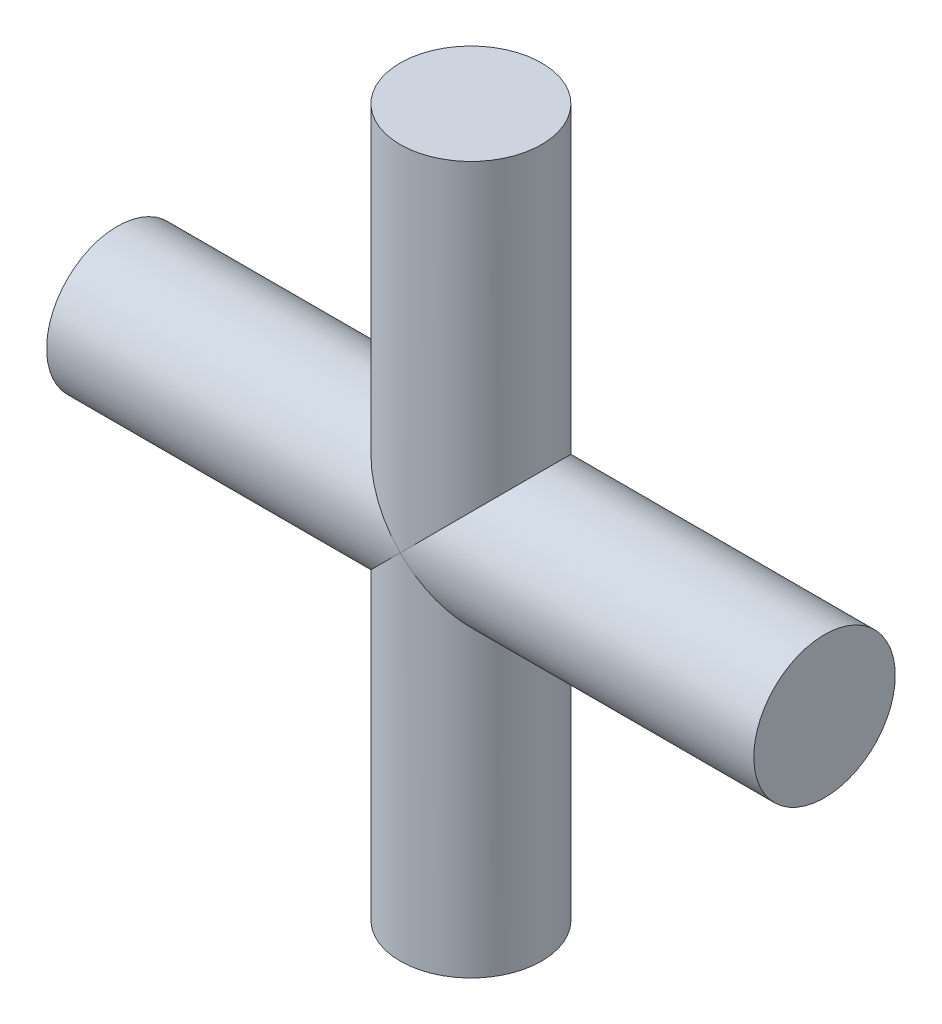
from build123d import *

# Parameters (mm, degrees)
SKIZZE2_R                       = 1
AUFSATZ_LINEAR_AUSTRAGEN1_DEPTH = 5
SKIZZE3_R                       = 1
AUFSATZ_LINEAR_AUSTRAGEN2_DEPTH = 5


with BuildPart() as part:
    # Skizze2 → Aufsatz-Linear austragen1 (new body, symmetric)
    with BuildSketch(Plane(origin=(0, 0, 0), x_dir=(1, 0, 0), z_dir=(0, 1, 0))):
        Circle(SKIZZE2_R)
    extrude(amount=AUFSATZ_LINEAR_AUSTRAGEN1_DEPTH, both=True)

    # Skizze3 → Aufsatz-Linear austragen2 (add, symmetric)
    with BuildSketch(Plane(origin=(0, 0, 0), x_dir=(0, 0, -1), z_dir=(1, 0, 0))):
        Circle(SKIZZE3_R)
    extrude(amount=AUFSATZ_LINEAR_AUSTRAGEN2_DEPTH, both=True)


solid = part.part
